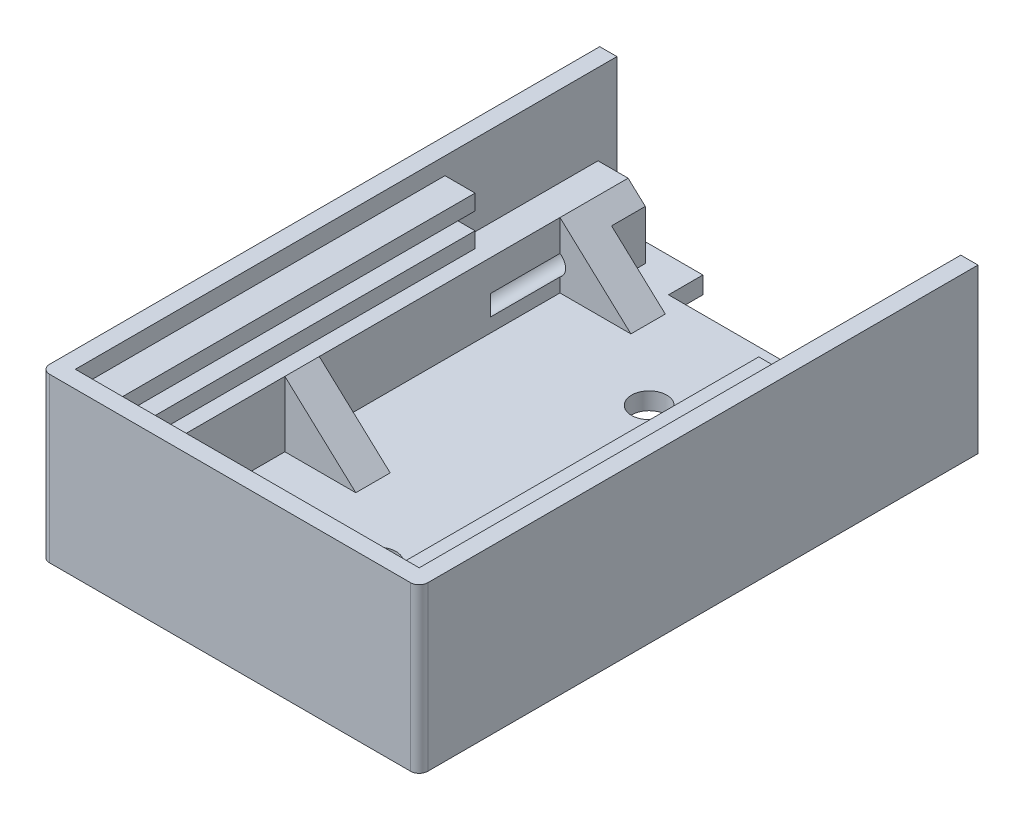
from build123d import *

# Parameters (mm, degrees)
ESBO_O1_W                = 44
ESBO_O1_H                = 65
RESSALTO_EXTRUS_O1_DEPTH = 19
ESBO_O2_W                = 40
ESBO_O2_H                = 15
CORTE_EXTRUS_O1_DEPTH    = 20
ESBO_O3_W                = 40
ESBO_O3_H                = 1.8
CORTE_EXTRUS_O2_DEPTH    = 43
ESBO_O4_W                = 33
ESBO_O4_H                = 7.6
CORTE_EXTRUS_O3_DEPTH    = 43
ESBO_O5_W                = 3.5
ESBO_O5_H                = 7.6
RESSALTO_EXTRUS_O2_DEPTH = 20
ESBO_O6_W                = 33
ESBO_O6_H                = 5.6
CORTE_EXTRUS_O4_DEPTH    = 43
ESBO_O7_W                = 3.5
ESBO_O7_H                = 2
ESBO_O7_W_2              = 40
CORTE_EXTRUS_O5_DEPTH    = 63
ESBO_O8_R                = 2.05
CORTE_EXTRUS_O6_DEPTH    = 3
ESBO_O9_W                = 3.5
ESBO_O9_H                = 7.601315145
CORTE_EXTRUS_O7_DEPTH    = 4
ESBO_O10_W               = 3.5
ESBO_O10_H               = 2
CORTE_EXTRUS_O9_DEPTH    = 16
ESBO_O12_W               = 8.25
ESBO_O12_H               = 4
ESBO_O12_W_2             = 4
ESBO_O12_H_2             = 7.625
RESSALTO_EXTRUS_O3_DEPTH = 8
CORTE_EXTRUS_O10_DEPTH   = 40
CORTE_EXTRUS_O11_DEPTH   = 24
RESSALTO_EXTRUS_O4_DEPTH = 1.8
ESBO_O18_W               = 3.925
ESBO_O18_H               = 5.6
RESSALTO_EXTRUS_O5_DEPTH = 2
CORTE_EXTRUS_O12_DEPTH   = 10
ESBO_O20_R               = 1.4
CORTE_EXTRUS_O13_DEPTH   = 16
ESBO_O21_W               = 3.925
ESBO_O21_H               = 7.6
RESSALTO_EXTRUS_O6_DEPTH = 2
CORTE_EXTRUS_O14_DEPTH   = 5
ESBO_O24_R               = 1.4
CORTE_EXTRUS_O15_DEPTH   = 16
ESBO_O26_W               = 20
ESBO_O26_H               = 2
CORTE_EXTRUS_O16_DEPTH   = 4
FILETE1_R                = 1


with BuildPart() as part:
    # Esboço1 → Ressalto-extrusão1 (new body)
    with BuildSketch(Plane(origin=(0, 0, 0), x_dir=(1, 0, 0), z_dir=(0, 1, 0))):
        Rectangle(ESBO_O1_W, ESBO_O1_H)
    extrude(amount=RESSALTO_EXTRUS_O1_DEPTH)

    # Esboço2 → Corte-extrusão1 (cut)
    with BuildSketch(Plane(origin=(0, 0, -32.5), x_dir=(-1, 0, 0), z_dir=(0, 0, -1))):
        with Locations((0, 9.5)):
            Rectangle(ESBO_O2_W, ESBO_O2_H)
    extrude(amount=-CORTE_EXTRUS_O1_DEPTH, mode=Mode.SUBTRACT)

    # Esboço3 → Corte-extrusão2 (cut)
    with BuildSketch(Plane(origin=(0, 0, -12.5), x_dir=(-1, 0, 0), z_dir=(0, 0, -1))):
        with Locations((0, 10.5)):
            Rectangle(ESBO_O3_W, ESBO_O3_H)
    extrude(amount=-CORTE_EXTRUS_O2_DEPTH, mode=Mode.SUBTRACT)

    # Esboço4 → Corte-extrusão3 (cut)
    with BuildSketch(Plane(origin=(0, 0, -12.5), x_dir=(-1, 0, 0), z_dir=(0, 0, -1))):
        with Locations((0, 5.8)):
            Rectangle(ESBO_O4_W, ESBO_O4_H)
    extrude(amount=-CORTE_EXTRUS_O3_DEPTH, mode=Mode.SUBTRACT)

    # Esboço5 → Ressalto-extrusão2 (add)
    with BuildSketch(Plane(origin=(0, 0, -12.5), x_dir=(-1, 0, 0), z_dir=(0, 0, -1))):
        with Locations((-18.25, 5.8)):
            Rectangle(ESBO_O5_W, ESBO_O5_H)
        with Locations((18.25, 5.8)):
            Rectangle(ESBO_O5_W, ESBO_O5_H)
    extrude(amount=RESSALTO_EXTRUS_O2_DEPTH)

    # Esboço6 → Corte-extrusão4 (cut)
    with BuildSketch(Plane(origin=(0, 0, -12.5), x_dir=(-1, 0, 0), z_dir=(0, 0, -1))):
        with Locations((0, 14.2)):
            Rectangle(ESBO_O6_W, ESBO_O6_H)
    extrude(amount=-CORTE_EXTRUS_O4_DEPTH, mode=Mode.SUBTRACT)

    # Esboço7 → Corte-extrusão5 (cut)
    with BuildSketch(Plane(origin=(0, 0, -32.5), x_dir=(-1, 0, 0), z_dir=(0, 0, -1))):
        with Locations((-18.25, 14.2)):
            Rectangle(ESBO_O7_W, ESBO_O7_H)
        with Locations((18.25, 14.2)):
            Rectangle(ESBO_O7_W, ESBO_O7_H)
        with Locations((0, 18)):
            Rectangle(ESBO_O7_W_2, ESBO_O7_H)
    extrude(amount=-CORTE_EXTRUS_O5_DEPTH, mode=Mode.SUBTRACT)

    # Esboço8 → Corte-extrusão6 (cut, through all)
    with BuildSketch(Plane(origin=(0, 2, 0), x_dir=(1, 0, 0), z_dir=(0, 1, 0))):
        with Locations((0, 16.25)):
            Circle(ESBO_O8_R)
        with Locations((0, -15.25)):
            Circle(ESBO_O8_R)
    extrude(amount=-CORTE_EXTRUS_O6_DEPTH, mode=Mode.SUBTRACT)

    # Esboço9 → Corte-extrusão7 (cut)
    with BuildSketch(Plane(origin=(0, 0, -32.5), x_dir=(-1, 0, 0), z_dir=(0, 0, -1))):
        with Locations((18.25, 5.799342428)):
            Rectangle(ESBO_O9_W, ESBO_O9_H)
        with Locations((-18.25, 5.799342428)):
            Rectangle(ESBO_O9_W, ESBO_O9_H)
    extrude(amount=-CORTE_EXTRUS_O7_DEPTH, mode=Mode.SUBTRACT)

    # Esboço10 → Corte-extrusão9 (cut)
    with BuildSketch(Plane(origin=(0, 0, -28.5), x_dir=(-1, 0, 0), z_dir=(0, 0, -1))):
        with Locations((-18.25, 8.6)):
            Rectangle(ESBO_O10_W, ESBO_O10_H)
    extrude(amount=-CORTE_EXTRUS_O9_DEPTH, mode=Mode.SUBTRACT)

    # Esboço12 → Ressalto-extrusão3 (add)
    with BuildSketch(Plane(origin=(0, 2, 0), x_dir=(1, 0, 0), z_dir=(0, 1, 0))):
        with Locations((12.375, 24.375)):
            Rectangle(ESBO_O12_W, ESBO_O12_H)
        with Locations((12.375, -7.625)):
            Rectangle(ESBO_O12_W, ESBO_O12_H)
        with Locations((8.25, -26.6875)):
            Rectangle(ESBO_O12_W_2, ESBO_O12_H_2)
        with Locations((-8.25, -26.6875)):
            Rectangle(ESBO_O12_W_2, ESBO_O12_H_2)
        with Locations((-12.375, -7.625)):
            Rectangle(ESBO_O12_W, ESBO_O12_H)
        with Locations((-12.375, 24.375)):
            Rectangle(ESBO_O12_W, ESBO_O12_H)
    extrude(amount=RESSALTO_EXTRUS_O3_DEPTH)

    # Esboço13 → Corte-extrusão10 (cut)
    with BuildSketch(Plane(origin=(0, 0, -26.375), x_dir=(-1, 0, 0), z_dir=(0, 0, -1))):
        Polygon((-8.25, 10), (-8.25, 2), (-16.5, 9.6), (-16.5, 10), align=None)
        Polygon((8.25, 2), (16.5, 9.6), (16.5, 10), (8.25, 10), align=None)
    extrude(amount=-CORTE_EXTRUS_O10_DEPTH, mode=Mode.SUBTRACT)

    # Esboço14 → Corte-extrusão11 (cut)
    with BuildSketch(Plane.ZY.offset(10.25)):
        Polygon((22.875, 2), (30.5, 9.625), (30.5, 10), (22.875, 10), align=None)
    extrude(amount=-CORTE_EXTRUS_O11_DEPTH, mode=Mode.SUBTRACT)

    # Esboço17 → Ressalto-extrusão4 (add)
    with BuildSketch(Plane(origin=(0, 0, -28.5), x_dir=(-1, 0, 0), z_dir=(0, 0, -1))):
        Polygon((-16.5, 2), (-16.5, 7.6), (-20, 7.6), (-20, 1.998684855), (-16.5, 1.998684855), align=None)
        Polygon((16.5, 9.6), (16.5, 2), (16.5, 1.998684855), (20, 1.998684855), (20, 9.6), align=None)
    extrude(amount=RESSALTO_EXTRUS_O4_DEPTH)

    # Esboço18 → Ressalto-extrusão5 (add)
    with BuildSketch(Plane.ZY.offset(-16.5)):
        with Locations((-28.3375, 4.8)):
            Rectangle(ESBO_O18_W, ESBO_O18_H)
    extrude(amount=RESSALTO_EXTRUS_O5_DEPTH)

    # Esboço19 → Corte-extrusão12 (cut)
    with BuildSketch(Plane(origin=(0, 0, -26.375), x_dir=(-1, 0, 0), z_dir=(0, 0, -1))):
        Polygon((-16.5, 9.6), (-16.5, 7.6), (-14.285160283, 7.559662806), align=None)
    extrude(amount=-CORTE_EXTRUS_O12_DEPTH, mode=Mode.SUBTRACT)

    # Esboço20 → Corte-extrusão13 (cut)
    with BuildSketch(Plane(origin=(0, 0, -30.3), x_dir=(-1, 0, 0), z_dir=(0, 0, -1))):
        with Locations((-17.25, 4.799342428)):
            Circle(ESBO_O20_R)
    extrude(amount=-CORTE_EXTRUS_O13_DEPTH, mode=Mode.SUBTRACT)

    # Esboço21 → Ressalto-extrusão6 (add)
    with BuildSketch(Plane(origin=(-16.5, 0, 0), x_dir=(0, 0, -1), z_dir=(1, 0, 0))):
        with Locations((28.3375, 5.8)):
            Rectangle(ESBO_O21_W, ESBO_O21_H)
    extrude(amount=RESSALTO_EXTRUS_O6_DEPTH)

    # Esboço23 → Corte-extrusão14 (cut)
    with BuildSketch(Plane(origin=(0, 0, -30.3), x_dir=(-1, 0, 0), z_dir=(0, 0, -1))):
        Polygon((13.624579494, 6.951127777), (17.102092839, 10.154655221), (13.624579494, 10.154655221), align=None)
    extrude(amount=-CORTE_EXTRUS_O14_DEPTH, mode=Mode.SUBTRACT)

    # Esboço24 → Corte-extrusão15 (cut)
    with BuildSketch(Plane(origin=(0, 0, -30.3), x_dir=(-1, 0, 0), z_dir=(0, 0, -1))):
        with Locations((17.25, 4.8)):
            Circle(ESBO_O24_R)
    extrude(amount=-CORTE_EXTRUS_O15_DEPTH, mode=Mode.SUBTRACT)

    # Esboço26 → Corte-extrusão16 (cut)
    with BuildSketch(Plane(origin=(0, 0, -32.5), x_dir=(-1, 0, 0), z_dir=(0, 0, -1))):
        with Locations((0, 1)):
            Rectangle(ESBO_O26_W, ESBO_O26_H)
    extrude(amount=-CORTE_EXTRUS_O16_DEPTH, mode=Mode.SUBTRACT)

    # Filete1
    filete1_edges = [part.edges().sort_by_distance(p)[0] for p in [
        (22, 9.5, 32.5),
        (-22, 9.5, 32.5),
    ]]
    fillet(filete1_edges, radius=FILETE1_R)


solid = part.part
